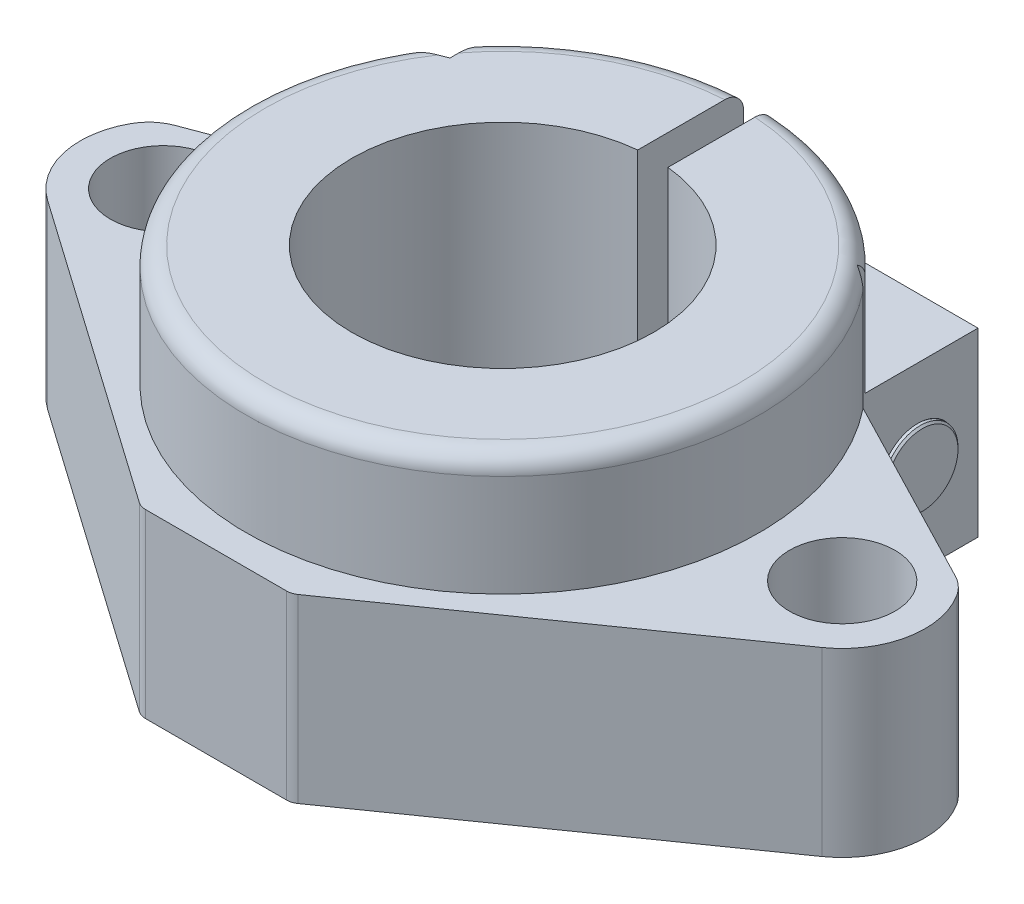
from build123d import *

# Parameters (mm, degrees)
SKETCH1_R                   = 3.5
BOSS_EXTRUDE1_DEPTH         = 12
SKETCH3_R                   = 17
BOSS_EXTRUDE2_DEPTH         = 8
FILLET1_R                   = 1.25
CUT_EXTRUDE1_DEPTH          = 36.902646142
CUT_EXTRUDE1_DEPTH_BACK     = 36.902646142
SKETCH4_R                   = 10
CUT_EXTRUDE2_DEPTH          = 40.306488113
CUT_EXTRUDE2_DEPTH_BACK     = 40.306488113
SKETCH5_W                   = 2
SKETCH5_H                   = 20
CUT_EXTRUDE3_DEPTH          = 40.306488113
CUT_EXTRUDE3_DEPTH_BACK     = 40.306488113
SKETCH7_R                   = 3
CUT_EXTRUDE4_DEPTH          = 12.5
FILLET2_R                   = 3
FILLET3_R                   = 1
M5_TAPPED_HOLE2_D           = 4.2
M5_TAPPED_HOLE2_CSINK_D     = 5.05
M5_TAPPED_HOLE2_CSINK_ANGLE = 90
SKETCH26_R                  = 2.5
BOSS_EXTRUDE4_DEPTH         = 0.001
BOSS_EXTRUDE4_DEPTH_BACK    = 25.5
SKETCH28_R                  = 4
BOSS_EXTRUDE5_DEPTH         = 5
CHAMFER1_SIZE               = 0.125
CUT_EXTRUDE5_DEPTH          = 3
FILLET4_R                   = 0.75


with BuildPart() as part:
    # Sketch1 → Boss-Extrude1 (new body)
    with BuildSketch(Plane(origin=(0, 0, 0), x_dir=(1, 0, 0), z_dir=(0, 1, 0))):
        with BuildLine():
            Line((5, -19), (-5, -19))
            Line((-5, -19), (-25.659364193, -4.502045968))
            ThreePointArc((-25.659364193, -4.502045968), (-27.968143757, -0.591103926), (-26.548475243, 3.722881707))
            Line((-26.548475243, 3.722881707), (-12.5, 19))
            Line((-12.5, 19), (12.5, 19))
            Line((12.5, 19), (26.548475243, 3.722881707))
            ThreePointArc((26.548475243, 3.722881707), (27.968143757, -0.591103926), (25.659364193, -4.502045968))
            Line((25.659364193, -4.502045968), (5, -19))
        make_face()
        with Locations(Location((-22.5, 0, 0), (0, 0, 270))):
            Circle(SKETCH1_R, mode=Mode.SUBTRACT)
        with Locations(Location((22.5, 0, 0), (0, 0, 90))):
            Circle(SKETCH1_R, mode=Mode.SUBTRACT)
    extrude(amount=BOSS_EXTRUDE1_DEPTH)

    # Sketch3 → Boss-Extrude2 (add)
    with BuildSketch(Plane(origin=(0, 12, 0), x_dir=(1, 0, 0), z_dir=(0, 1, 0))):
        with Locations(Location((0, 0, 0), (0, 0, 270))):
            Circle(SKETCH3_R)
    extrude(amount=BOSS_EXTRUDE2_DEPTH)

    # Fillet1
    fillet1_edges = [part.edges().sort_by_distance(p)[0] for p in [
        (0, 20, -17),
    ]]
    fillet(fillet1_edges, radius=FILLET1_R)

    # Sketch2 → Cut-Extrude1 (cut, two sides)
    with BuildSketch(Plane(origin=(0, 12, 0), x_dir=(1, 0, 0), z_dir=(0, 1, 0))) as cut_extrude1_sk:
        Polygon((12.5, 19), (12.5, 11), (26.548475243, 3.722881707), align=None)
        Polygon((-12.5, 19), (-12.5, 8.999645995), (-26.548475243, 3.722881707), align=None)
    extrude(amount=CUT_EXTRUDE1_DEPTH, mode=Mode.SUBTRACT)
    extrude(cut_extrude1_sk.sketch, amount=-CUT_EXTRUDE1_DEPTH_BACK, mode=Mode.SUBTRACT)

    # Sketch4 → Cut-Extrude2 (cut, two sides)
    with BuildSketch(Plane(origin=(0, 20, 0), x_dir=(1, 0, 0), z_dir=(0, 1, 0))) as cut_extrude2_sk:
        with Locations(Location((0, 0, 0), (0, 0, 270))):
            Circle(SKETCH4_R)
    extrude(amount=CUT_EXTRUDE2_DEPTH, mode=Mode.SUBTRACT)
    extrude(cut_extrude2_sk.sketch, amount=-CUT_EXTRUDE2_DEPTH_BACK, mode=Mode.SUBTRACT)

    # Sketch5 → Cut-Extrude3 (cut, two sides)
    with BuildSketch(Plane(origin=(0, 20, 0), x_dir=(1, 0, 0), z_dir=(0, 1, 0))) as cut_extrude3_sk:
        with Locations((0, 10)):
            Rectangle(SKETCH5_W, SKETCH5_H)
    extrude(amount=CUT_EXTRUDE3_DEPTH, mode=Mode.SUBTRACT)
    extrude(cut_extrude3_sk.sketch, amount=-CUT_EXTRUDE3_DEPTH_BACK, mode=Mode.SUBTRACT)

    # Sketch7 → Cut-Extrude4 (cut)
    with BuildSketch(Plane.ZY.offset(12.5)):
        with Locations((-15, 6)):
            Circle(SKETCH7_R)
    extrude(amount=-CUT_EXTRUDE4_DEPTH, mode=Mode.SUBTRACT)

    # Fillet2
    fillet2_edges = [part.edges().sort_by_distance(p)[0] for p in [
        (26.548475243, 6, -3.722881707),
        (-26.548475243, 6, -3.722881707),
    ]]
    fillet(fillet2_edges, radius=FILLET2_R)

    # Fillet3
    fillet3_edges = [part.edges().sort_by_distance(p)[0] for p in [
        (5, 6, 19),
        (-5, 6, 19),
    ]]
    fillet(fillet3_edges, radius=FILLET3_R)

    # M5 Tapped Hole2 (through all)
    with Locations(Plane(origin=(12.5, 0, 0), x_dir=(0, 0, -1), z_dir=(1, 0, 0))):
        with Locations((15, 6)):
            CounterSinkHole(M5_TAPPED_HOLE2_D / 2, M5_TAPPED_HOLE2_CSINK_D / 2, counter_sink_angle=M5_TAPPED_HOLE2_CSINK_ANGLE)



with BuildPart() as body_2:
    # Sketch26 → Boss-Extrude4 (new, two sides)
    with BuildSketch(Plane.ZY.offset(12.7)) as boss_extrude4_sk:
        with Locations((-15, 6)):
            Circle(SKETCH26_R)
    extrude(amount=BOSS_EXTRUDE4_DEPTH)
    extrude(boss_extrude4_sk.sketch, amount=-BOSS_EXTRUDE4_DEPTH_BACK)


with BuildPart() as part_1:
    add(part.part)

    add(body_2.part)  # Boss-Extrude5 merges body 2
    # Sketch28 → Boss-Extrude5 (add)
    with BuildSketch(Plane.ZY.offset(12.701)):
        with Locations((-15, 6)):
            Circle(SKETCH28_R)
    extrude(amount=BOSS_EXTRUDE5_DEPTH)

    # Chamfer1
    chamfer1_edges = [part_1.edges().sort_by_distance(p)[0] for p in [
        (12.8, 6, -17.5),
    ]]
    chamfer(chamfer1_edges, length=CHAMFER1_SIZE)

    # Sketch29 → Cut-Extrude5 (cut)
    with BuildSketch(Plane.ZY.offset(17.701)):
        Polygon((-15, 8.309401077), (-17, 7.154700538), (-17, 4.845299462), (-15, 3.690598923), (-13, 4.845299462), (-13, 7.154700538), align=None)
    extrude(amount=-CUT_EXTRUDE5_DEPTH, mode=Mode.SUBTRACT)

    # Fillet4
    fillet4_edges = [part_1.edges().sort_by_distance(p)[0] for p in [
        (-17.701, 6, -19),
    ]]
    fillet(fillet4_edges, radius=FILLET4_R)


solid = part_1.part
